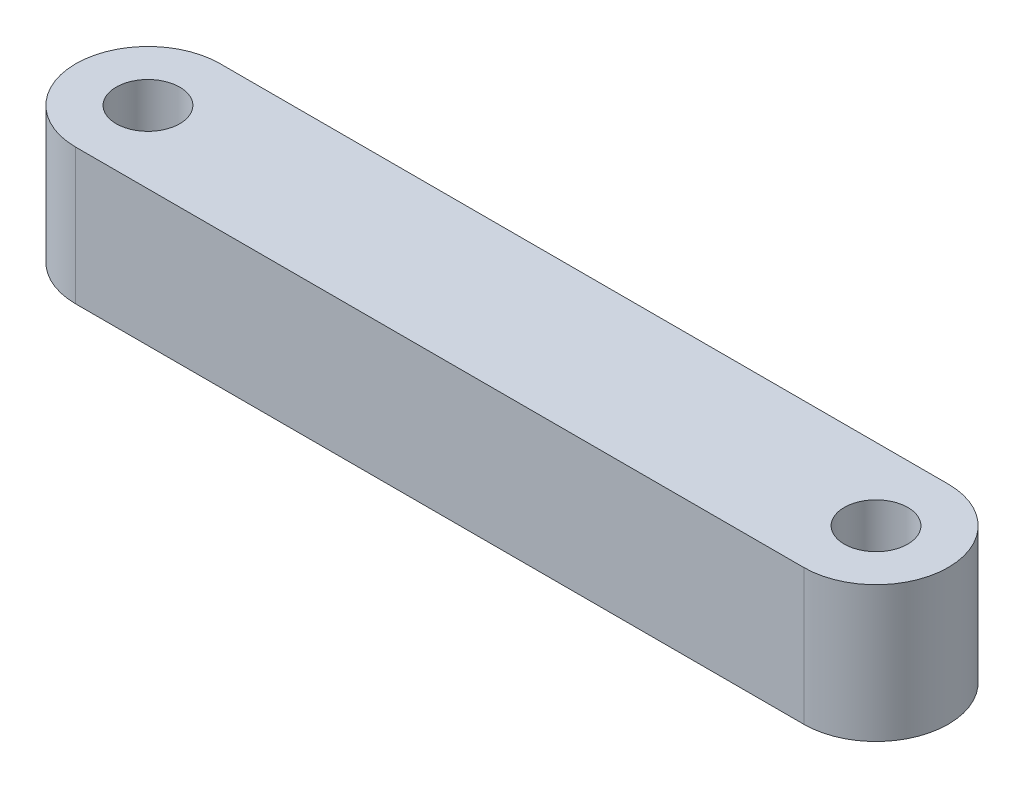
from build123d import *

# Parameters (mm, degrees)
SKETCH1_R           = 1.397
BOSS_EXTRUDE1_DEPTH = 5.969


with BuildPart() as part:
    # Sketch1 → Boss-Extrude1 (new body)
    with BuildSketch(Plane(origin=(0, 0, 0), x_dir=(1, 0, 0), z_dir=(0, 1, 0))):
        with BuildLine():
            Line((-16, 3.175), (16, 3.175))
            ThreePointArc((16, 3.175), (19.175, 0), (16, -3.175))
            Line((16, -3.175), (-16, -3.175))
            ThreePointArc((-16, -3.175), (-19.175, 0), (-16, 3.175))
        make_face()
        with Locations((-16, 0)):
            Circle(SKETCH1_R, mode=Mode.SUBTRACT)
        with Locations((16, 0)):
            Circle(SKETCH1_R, mode=Mode.SUBTRACT)
    extrude(amount=BOSS_EXTRUDE1_DEPTH)


solid = part.part
